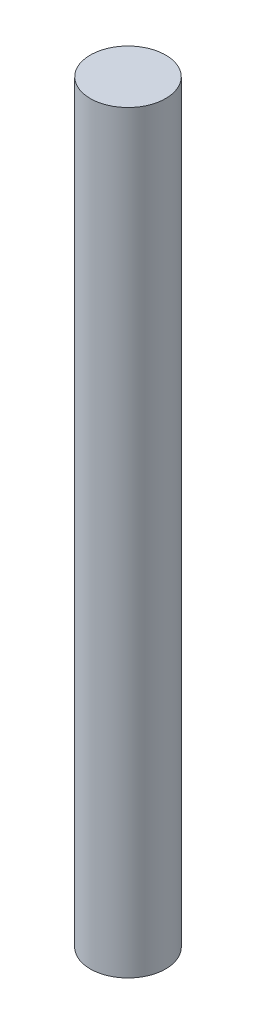
from build123d import *

# Parameters (mm, degrees)
CROQUIS1_R              = 4
SALIENTE_EXTRUIR1_DEPTH = 80


with BuildPart() as part:
    # Croquis1 → Saliente-Extruir1 (new body)
    with BuildSketch(Plane(origin=(0, 0, 0), x_dir=(1, 0, 0), z_dir=(0, 1, 0))):
        Circle(CROQUIS1_R)
    extrude(amount=SALIENTE_EXTRUIR1_DEPTH)


solid = part.part
